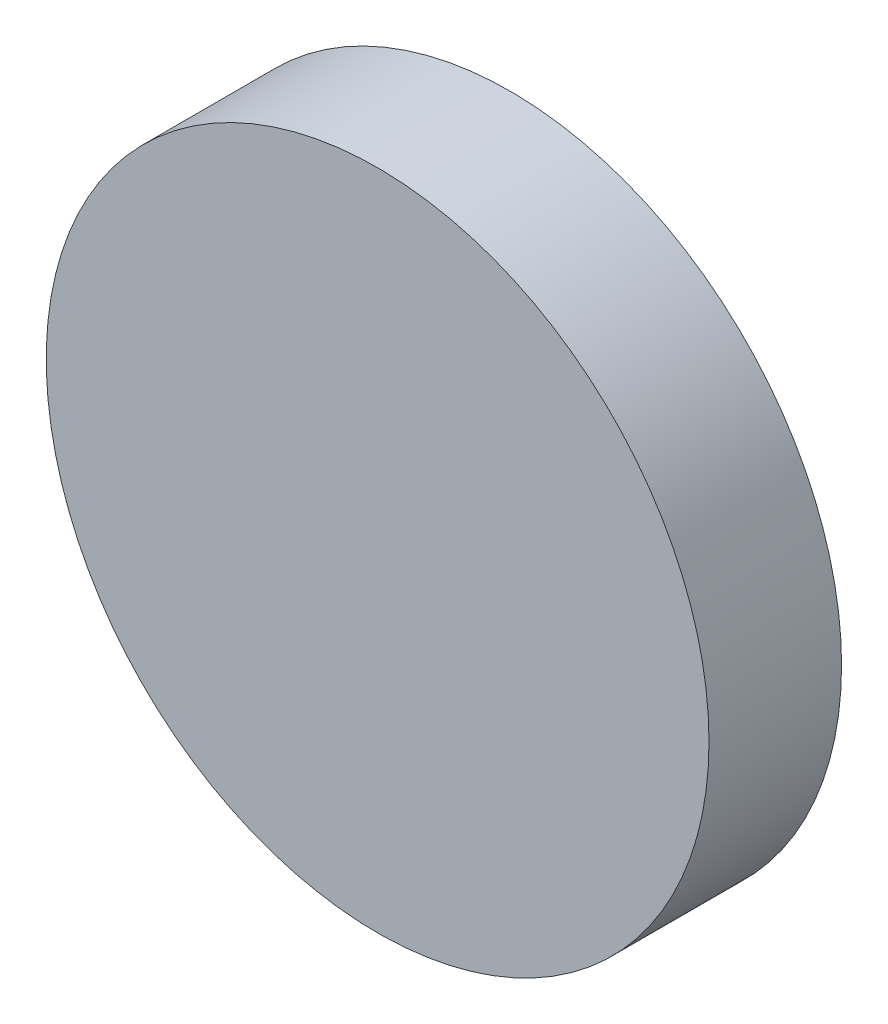
from build123d import *

# Parameters (mm, degrees)
SKIZZE4_R                       = 50
AUFSATZ_LINEAR_AUSTRAGEN1_DEPTH = 20


with BuildPart() as part:
    # Skizze4 → Aufsatz-Linear austragen1 (new body)
    with BuildSketch(Plane.XY):
        Circle(SKIZZE4_R)
    extrude(amount=-AUFSATZ_LINEAR_AUSTRAGEN1_DEPTH)


solid = part.part
